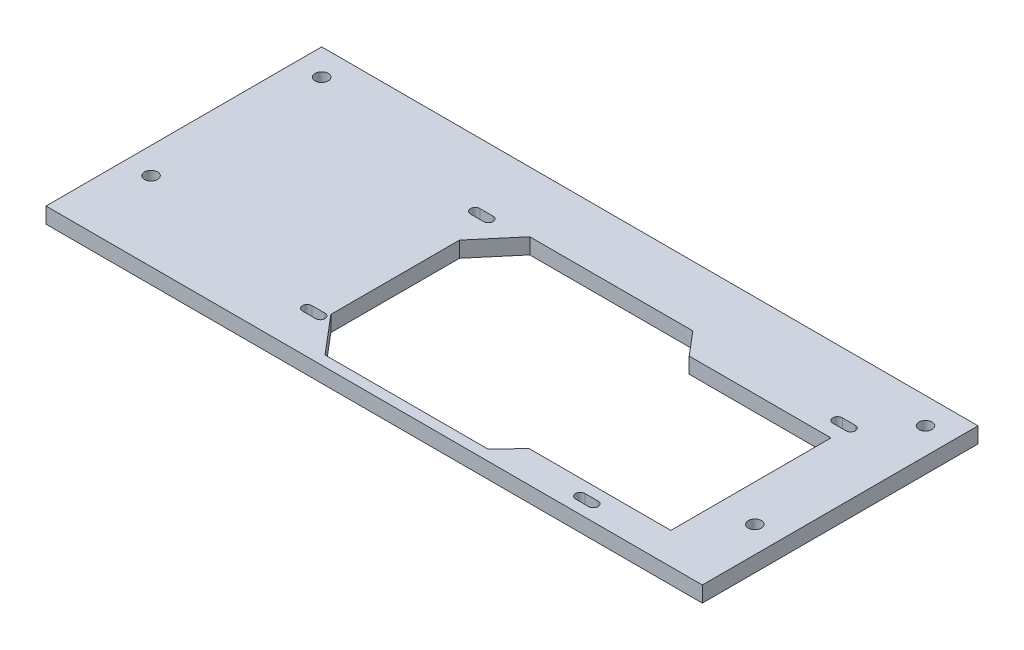
from build123d import *

# Parameters (mm, degrees)
SKETCH1_W           = 250
SKETCH1_H           = 105
BOSS_EXTRUDE1_DEPTH = 6
SKETCH1_4_R         = 2.5
CUT_EXTRUDE1_DEPTH  = 6


with BuildPart() as part:
    # Sketch1 → Boss-Extrude1 (new body)
    with BuildSketch(Plane(origin=(0, 0, 0), x_dir=(1, 0, 0), z_dir=(0, 1, 0))):
        Rectangle(SKETCH1_W, SKETCH1_H)
    extrude(amount=BOSS_EXTRUDE1_DEPTH)

    # Sketch1_4 → Cut-Extrude1 (cut)
    with BuildSketch(Plane(origin=(0, 0, 0), x_dir=(1, 0, 0), z_dir=(0, 1, 0))):
        with Locations((-115, -22.5)):
            Circle(SKETCH1_4_R)
        with Locations((-115, 42.5)):
            Circle(SKETCH1_4_R)
        with Locations((115, 42.5)):
            Circle(SKETCH1_4_R)
        with Locations((115, -22.5)):
            Circle(SKETCH1_4_R)
        Polygon((-22.728448276, 29.5), (39.383174792, 29.5), (47, 20.5), (101, 20.5), (101, -40.5), (47, -40.5), (39.383174792, -48.5), (-22.728448276, -48.5), (-35, -34), (-35, 15), align=None)
        with BuildLine():
            Line((72.5, -44.7), (77.5, -44.7))
            ThreePointArc((77.5, -44.7), (79.3, -46.5), (77.5, -48.3))
            Line((77.5, -48.3), (72.5, -48.3))
            ThreePointArc((72.5, -48.3), (70.7, -46.5), (72.5, -44.7))
        make_face()
        with BuildLine():
            Line((96.5, 29.3), (101.5, 29.3))
            ThreePointArc((101.5, 29.3), (103.3, 27.5), (101.5, 25.7))
            Line((101.5, 25.7), (96.5, 25.7))
            ThreePointArc((96.5, 25.7), (94.7, 27.5), (96.5, 29.3))
        make_face()
        with BuildLine():
            Line((-41.5, 29.3), (-36.5, 29.3))
            ThreePointArc((-36.5, 29.3), (-34.7, 27.5), (-36.5, 25.7))
            Line((-36.5, 25.7), (-41.5, 25.7))
            ThreePointArc((-41.5, 25.7), (-43.3, 27.5), (-41.5, 29.3))
        make_face()
        with BuildLine():
            Line((-41.5, -34.7), (-36.5, -34.7))
            ThreePointArc((-36.5, -34.7), (-34.7, -36.5), (-36.5, -38.3))
            Line((-36.5, -38.3), (-41.5, -38.3))
            ThreePointArc((-41.5, -38.3), (-43.3, -36.5), (-41.5, -34.7))
        make_face()
    extrude(amount=CUT_EXTRUDE1_DEPTH, mode=Mode.SUBTRACT)


solid = part.part
